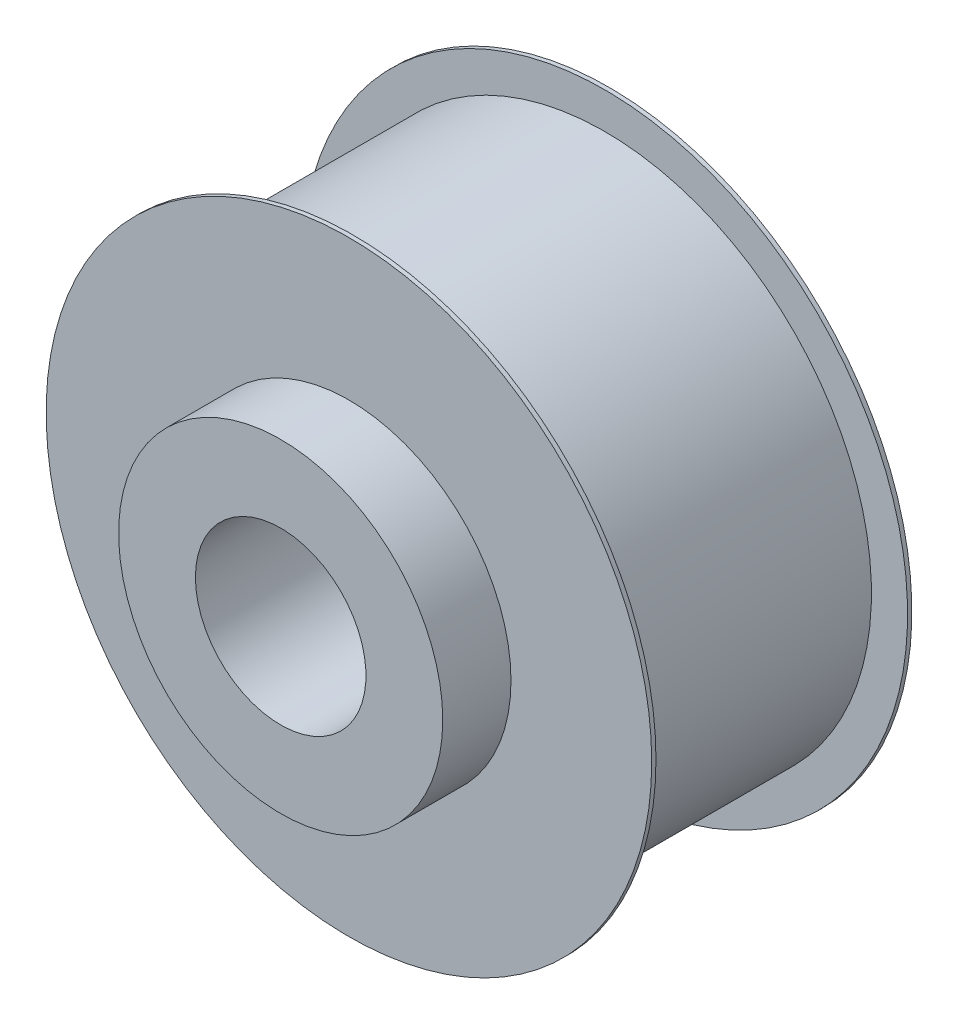
from build123d import *

# Parameters (mm, degrees)
SZKIC1_R                    = 31.26
DODANIE_WYCI_GNI_CIE1_DEPTH = 30.5
SZKIC2_R                    = 19
DODANIE_WYCI_GNI_CIE2_DEPTH = 8
SZKIC3_R                    = 35.5
DODANIE_WYCI_GNI_CIE3_DEPTH = 0.5
SZKIC7_R                    = 35.5
DODANIE_WYCI_GNI_CIE4_DEPTH = 0.5
SZKIC8_R                    = 10
WYTNIJ_WYCI_GNI_CIE4_DEPTH  = 39.5


with BuildPart() as part:
    # Szkic1 → Dodanie-wyciągnięcie1 (new body)
    with BuildSketch(Plane.XY):
        Circle(SZKIC1_R)
    extrude(amount=DODANIE_WYCI_GNI_CIE1_DEPTH)

    # Szkic2 → Dodanie-wyciągnięcie2 (add)
    with BuildSketch(Plane.XY.offset(30.5)):
        Circle(SZKIC2_R)
    extrude(amount=DODANIE_WYCI_GNI_CIE2_DEPTH)

    # Szkic3 → Dodanie-wyciągnięcie3 (add)
    with BuildSketch(Plane.XY.offset(30.5)):
        Circle(SZKIC3_R)
    extrude(amount=-DODANIE_WYCI_GNI_CIE3_DEPTH)

    # Szkic7 → Dodanie-wyciągnięcie4 (add)
    with BuildSketch(Plane(origin=(0, 0, 0), x_dir=(-1, 0, 0), z_dir=(0, 0, -1))):
        Circle(SZKIC7_R)
    extrude(amount=-DODANIE_WYCI_GNI_CIE4_DEPTH)

    # Szkic8 → Wytnij-wyciągnięcie4 (cut, through all)
    with BuildSketch(Plane(origin=(0, 0, 0), x_dir=(-1, 0, 0), z_dir=(0, 0, -1))):
        Circle(SZKIC8_R)
    extrude(amount=-WYTNIJ_WYCI_GNI_CIE4_DEPTH, mode=Mode.SUBTRACT)


solid = part.part
